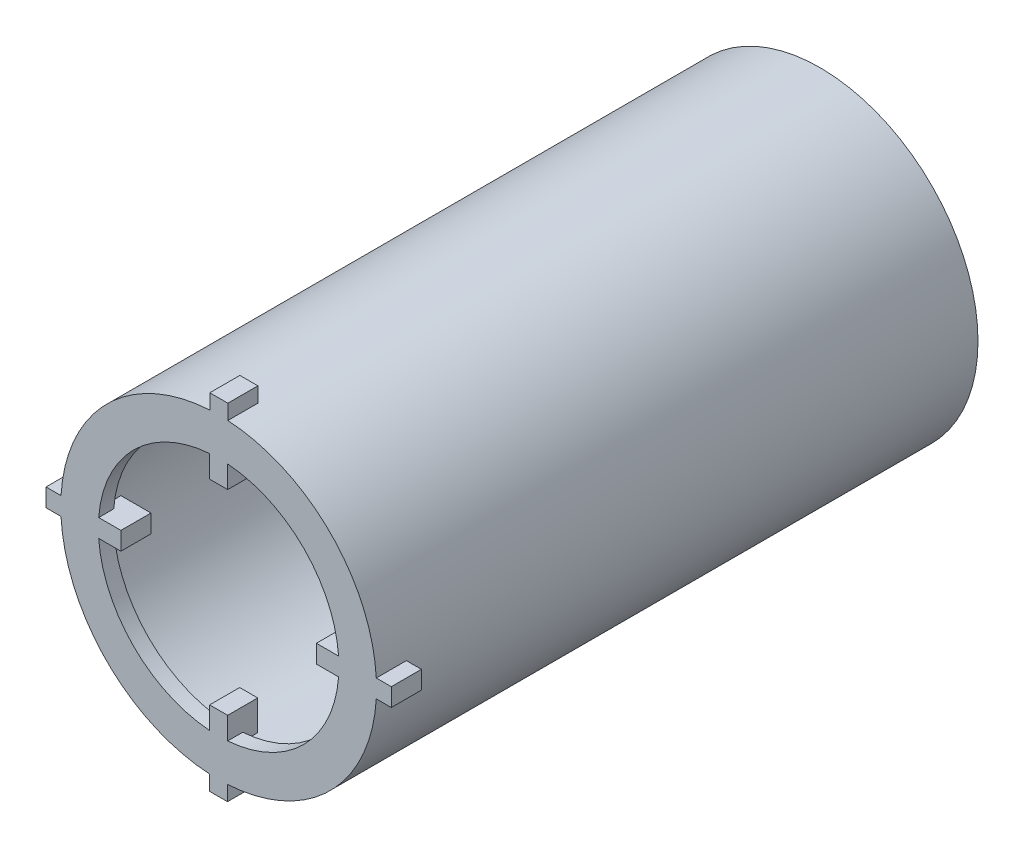
from build123d import *

# Parameters (mm, degrees)
SKETCH_1_R               = 10.5
SKETCH_1_R_2             = 9.5
EXTRUDE_1_DEPTH          = 40
SKETCH_2_R               = 10.5
EXTRUDE_2_DEPTH          = 1
SKETCH_3_R               = 0.492995
CUT_EXTRUDE_1_DEPTH      = 1
EXTRUDE_START            = 40
SKETCH_6_R               = 10
SKETCH_6_R_2             = 8
EXTRUDE_3_DEPTH          = 1
SKETCH_5_W               = 2
SKETCH_5_H               = 1.2
EXTRUDE_4_DEPTH          = 2
PATTERN_CIRCULAR_1_COUNT = 4


with BuildPart() as part:
    # ｽｹｯﾁ1 → ﾎﾞｽ - 押し出し1 (new body)
    with BuildSketch(Plane.XY):
        Circle(SKETCH_1_R)
        Circle(SKETCH_1_R_2, mode=Mode.SUBTRACT)
    extrude(amount=EXTRUDE_1_DEPTH)

    # ｽｹｯﾁ2 → ﾎﾞｽ - 押し出し2 (add)
    with BuildSketch(Plane.XY):
        Circle(SKETCH_2_R)
    extrude(amount=EXTRUDE_2_DEPTH)

    # ｽｹｯﾁ3 → ｶｯﾄ - 押し出し1 (cut)
    with BuildSketch(Plane.XY):
        with Locations((4.413132646, 3.597662483)):
            Circle(SKETCH_3_R)
    extrude(amount=CUT_EXTRUDE_1_DEPTH, mode=Mode.SUBTRACT)

    # ｽｹｯﾁ6 → ﾎﾞｽ - 押し出し3 (add)
    with BuildSketch(Plane.XY.offset(EXTRUDE_START)):
        Circle(SKETCH_6_R)
        Circle(SKETCH_6_R_2, mode=Mode.SUBTRACT)
    extrude(amount=-EXTRUDE_3_DEPTH)

    # ｽｹｯﾁ5 → ﾎﾞｽ - 押し出し4 (add)
    with BuildSketch(Plane.XY.offset(40)):
        with Locations((7.5, 0)):
            Rectangle(SKETCH_5_W, SKETCH_5_H)
        with Locations((10.48172138, -0.010967172)):
            Rectangle(SKETCH_5_W, SKETCH_5_H)
    extrude_4 = extrude(amount=-EXTRUDE_4_DEPTH)

    # 円形ﾊﾟﾀｰﾝ1: ﾎﾞｽ - 押し出し4 ×4 about axis
    pattern_circular_1_axis = Axis((0, 0, 0), (0, 0, 1))
    for i in range(1, PATTERN_CIRCULAR_1_COUNT):
        add(extrude_4.rotate(pattern_circular_1_axis, i * 360 / PATTERN_CIRCULAR_1_COUNT))


solid = part.part
